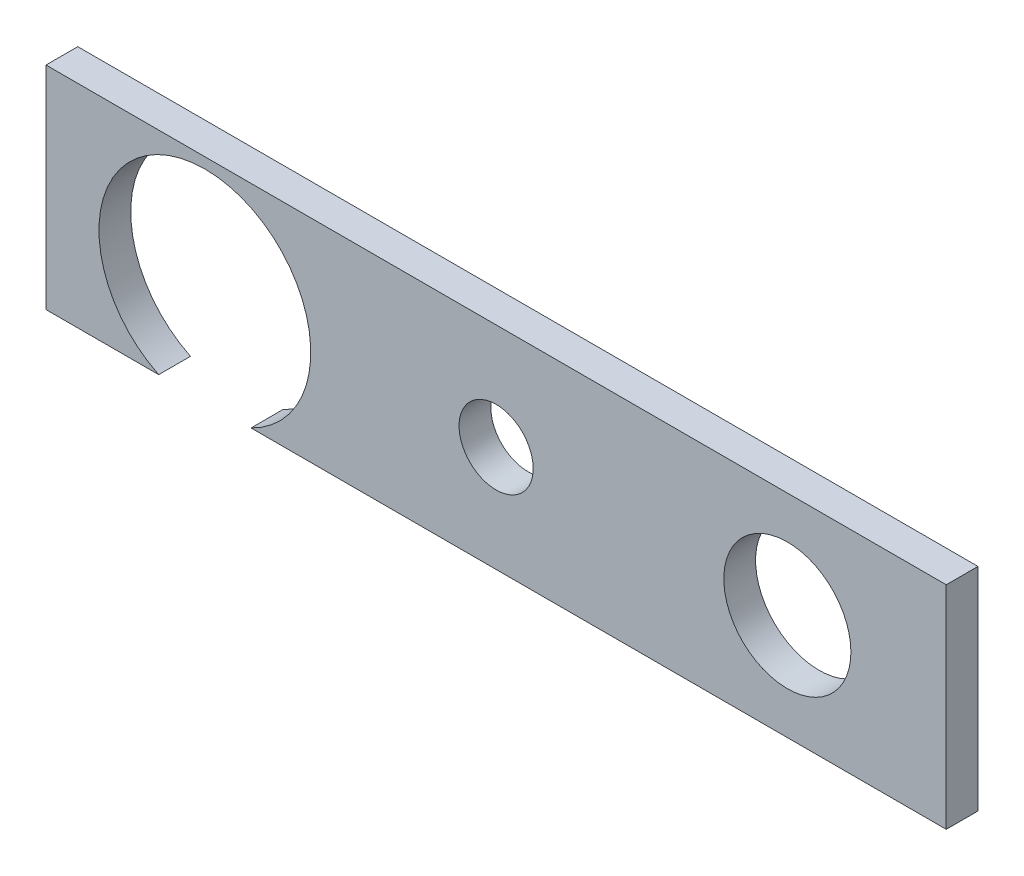
from build123d import *

# Parameters (mm, degrees)
SKETCH1_W           = 85
SKETCH1_H           = 20
BOSS_EXTRUDE1_DEPTH = 3
SKETCH2_R           = 3.5
SKETCH2_R_2         = 6
SKETCH2_R_3         = 10
CUT_EXTRUDE1_DEPTH  = 4


with BuildPart() as part:
    # Sketch1 → Boss-Extrude1 (new body)
    with BuildSketch(Plane.XY):
        with Locations((42.5, 10)):
            Rectangle(SKETCH1_W, SKETCH1_H)
    extrude(amount=BOSS_EXTRUDE1_DEPTH)

    # Sketch2 → Cut-Extrude1 (cut, through all)
    with BuildSketch(Plane.XY.offset(3)):
        with Locations((42.5, 10)):
            Circle(SKETCH2_R)
        with Locations((70, 10)):
            Circle(SKETCH2_R_2)
        with Locations((15, 9)):
            Circle(SKETCH2_R_3)
    extrude(amount=-CUT_EXTRUDE1_DEPTH, mode=Mode.SUBTRACT)


solid = part.part
